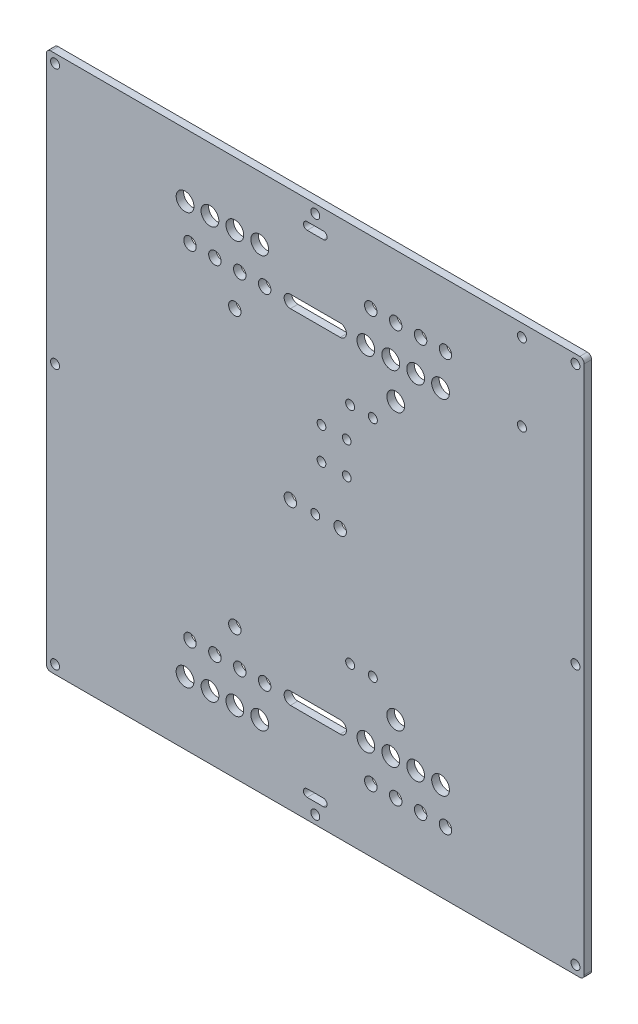
from build123d import *

# Parameters (mm, degrees)
SKETCH1_R           = 1.8
SKETCH1_R_2         = 3.57
SKETCH1_R_3         = 2.5
SKETCH1_R_4         = 1.75
BOSS_EXTRUDE1_DEPTH = 1.5


with BuildPart() as part:
    # Sketch1 → Boss-Extrude1 (new body, symmetric)
    with BuildSketch(Plane.XY):
        with BuildLine():
            Line((-106.25, -108), (106.25, -108))
            ThreePointArc((106.25, -108), (107.487436867, -107.487436867), (108, -106.25))
            Line((108, -106.25), (108, 106.25))
            ThreePointArc((108, 106.25), (107.487436867, 107.487436867), (106.25, 108))
            Line((106.25, 108), (-106.25, 108))
            ThreePointArc((-106.25, 108), (-107.487436867, 107.487436867), (-108, 106.25))
            Line((-108, 106.25), (-108, -106.25))
            ThreePointArc((-108, -106.25), (-107.487436867, -107.487436867), (-106.25, -108))
        make_face()
        with Locations((-104.5, 104.5)):
            Circle(SKETCH1_R, mode=Mode.SUBTRACT)
        with Locations((0, 104.5)):
            Circle(SKETCH1_R, mode=Mode.SUBTRACT)
        with Locations((104.5, 104.5)):
            Circle(SKETCH1_R, mode=Mode.SUBTRACT)
        with Locations((-104.5, 0)):
            Circle(SKETCH1_R, mode=Mode.SUBTRACT)
        Circle(SKETCH1_R, mode=Mode.SUBTRACT)
        with Locations((104.5, 0)):
            Circle(SKETCH1_R, mode=Mode.SUBTRACT)
        with Locations((-104.5, -104.5)):
            Circle(SKETCH1_R, mode=Mode.SUBTRACT)
        with Locations((0, -104.5)):
            Circle(SKETCH1_R, mode=Mode.SUBTRACT)
        with Locations((104.5, -104.5)):
            Circle(SKETCH1_R, mode=Mode.SUBTRACT)
        with Locations((-52.3, -82.65)):
            Circle(SKETCH1_R_2, mode=Mode.SUBTRACT)
        with Locations((-42.3, -82.65)):
            Circle(SKETCH1_R_2, mode=Mode.SUBTRACT)
        with Locations((-32.3, -82.65)):
            Circle(SKETCH1_R_2, mode=Mode.SUBTRACT)
        with Locations((-22.3, -82.65)):
            Circle(SKETCH1_R_2, mode=Mode.SUBTRACT)
        with Locations((-50.32, -69)):
            Circle(SKETCH1_R_3, mode=Mode.SUBTRACT)
        with Locations((-40.32, -69)):
            Circle(SKETCH1_R_3, mode=Mode.SUBTRACT)
        with Locations((-30.32, -69)):
            Circle(SKETCH1_R_3, mode=Mode.SUBTRACT)
        with Locations((-20.32, -69)):
            Circle(SKETCH1_R_3, mode=Mode.SUBTRACT)
        with Locations((42.3, -82.65)):
            Circle(SKETCH1_R_3, mode=Mode.SUBTRACT)
        with Locations((32.3, -82.65)):
            Circle(SKETCH1_R_3, mode=Mode.SUBTRACT)
        with Locations((22.3, -82.65)):
            Circle(SKETCH1_R_3, mode=Mode.SUBTRACT)
        with Locations((52.3, -82.65)):
            Circle(SKETCH1_R_3, mode=Mode.SUBTRACT)
        with Locations((50.32, -69)):
            Circle(SKETCH1_R_2, mode=Mode.SUBTRACT)
        with Locations((40.32, -69)):
            Circle(SKETCH1_R_2, mode=Mode.SUBTRACT)
        with Locations((30.32, -69)):
            Circle(SKETCH1_R_2, mode=Mode.SUBTRACT)
        with Locations((20.32, -69)):
            Circle(SKETCH1_R_2, mode=Mode.SUBTRACT)
        with Locations((-32.3, -55.35)):
            Circle(SKETCH1_R_3, mode=Mode.SUBTRACT)
        with Locations((32.3, -55.35)):
            Circle(SKETCH1_R_2, mode=Mode.SUBTRACT)
        with Locations((14, -45)):
            Circle(SKETCH1_R, mode=Mode.SUBTRACT)
        with Locations((23.12, -45)):
            Circle(SKETCH1_R, mode=Mode.SUBTRACT)
        with Locations((-10, 0)):
            Circle(SKETCH1_R_3, mode=Mode.SUBTRACT)
        with Locations((10, 0)):
            Circle(SKETCH1_R_3, mode=Mode.SUBTRACT)
        with Locations((2.5, 32.3)):
            Circle(SKETCH1_R_4, mode=Mode.SUBTRACT)
        with Locations((12.64, 32.3)):
            Circle(SKETCH1_R_4, mode=Mode.SUBTRACT)
        with Locations((2.5, 19.47)):
            Circle(SKETCH1_R_4, mode=Mode.SUBTRACT)
        with Locations((12.64, 19.47)):
            Circle(SKETCH1_R_4, mode=Mode.SUBTRACT)
        with Locations((23.12, 45)):
            Circle(SKETCH1_R, mode=Mode.SUBTRACT)
        with Locations((14, 45)):
            Circle(SKETCH1_R, mode=Mode.SUBTRACT)
        with Locations((32.3, 55.35)):
            Circle(SKETCH1_R_2, mode=Mode.SUBTRACT)
        with Locations((-32.3, 55.35)):
            Circle(SKETCH1_R_3, mode=Mode.SUBTRACT)
        with Locations((20.32, 69)):
            Circle(SKETCH1_R_2, mode=Mode.SUBTRACT)
        with Locations((30.32, 69)):
            Circle(SKETCH1_R_2, mode=Mode.SUBTRACT)
        with Locations((40.32, 69)):
            Circle(SKETCH1_R_2, mode=Mode.SUBTRACT)
        with Locations((50.32, 69)):
            Circle(SKETCH1_R_2, mode=Mode.SUBTRACT)
        with Locations((52.3, 82.65)):
            Circle(SKETCH1_R_3, mode=Mode.SUBTRACT)
        with Locations((22.3, 82.65)):
            Circle(SKETCH1_R_3, mode=Mode.SUBTRACT)
        with Locations((32.3, 82.65)):
            Circle(SKETCH1_R_3, mode=Mode.SUBTRACT)
        with Locations((42.3, 82.65)):
            Circle(SKETCH1_R_3, mode=Mode.SUBTRACT)
        with Locations((-20.32, 69)):
            Circle(SKETCH1_R_3, mode=Mode.SUBTRACT)
        with Locations((-30.32, 69)):
            Circle(SKETCH1_R_3, mode=Mode.SUBTRACT)
        with Locations((-40.32, 69)):
            Circle(SKETCH1_R_3, mode=Mode.SUBTRACT)
        with Locations((-50.32, 69)):
            Circle(SKETCH1_R_3, mode=Mode.SUBTRACT)
        with Locations((-22.3, 82.65)):
            Circle(SKETCH1_R_2, mode=Mode.SUBTRACT)
        with Locations((-32.3, 82.65)):
            Circle(SKETCH1_R_2, mode=Mode.SUBTRACT)
        with Locations((-42.3, 82.65)):
            Circle(SKETCH1_R_2, mode=Mode.SUBTRACT)
        with Locations((-52.3, 82.65)):
            Circle(SKETCH1_R_2, mode=Mode.SUBTRACT)
        with Locations((83, 103)):
            Circle(SKETCH1_R, mode=Mode.SUBTRACT)
        with Locations((83, 72)):
            Circle(SKETCH1_R, mode=Mode.SUBTRACT)
        with BuildLine():
            Line((-3.25, -97.12), (3.25, -97.12))
            ThreePointArc((3.25, -97.12), (4.75, -98.62), (3.25, -100.12))
            Line((3.25, -100.12), (-3.25, -100.12))
            ThreePointArc((-3.25, -100.12), (-4.75, -98.62), (-3.25, -97.12))
        make_face(mode=Mode.SUBTRACT)
        with BuildLine():
            Line((-10, -66.5), (10, -66.5))
            ThreePointArc((10, -66.5), (12.5, -69), (10, -71.5))
            Line((10, -71.5), (-10, -71.5))
            ThreePointArc((-10, -71.5), (-12.5, -69), (-10, -66.5))
        make_face(mode=Mode.SUBTRACT)
        with BuildLine():
            Line((-3.25, 97.12), (3.25, 97.12))
            ThreePointArc((3.25, 97.12), (4.75, 98.62), (3.25, 100.12))
            Line((3.25, 100.12), (-3.25, 100.12))
            ThreePointArc((-3.25, 100.12), (-4.75, 98.62), (-3.25, 97.12))
        make_face(mode=Mode.SUBTRACT)
        with BuildLine():
            Line((-10, 66.5), (10, 66.5))
            ThreePointArc((10, 66.5), (12.5, 69), (10, 71.5))
            Line((10, 71.5), (-10, 71.5))
            ThreePointArc((-10, 71.5), (-12.5, 69), (-10, 66.5))
        make_face(mode=Mode.SUBTRACT)
    extrude(amount=BOSS_EXTRUDE1_DEPTH, both=True)


solid = part.part
